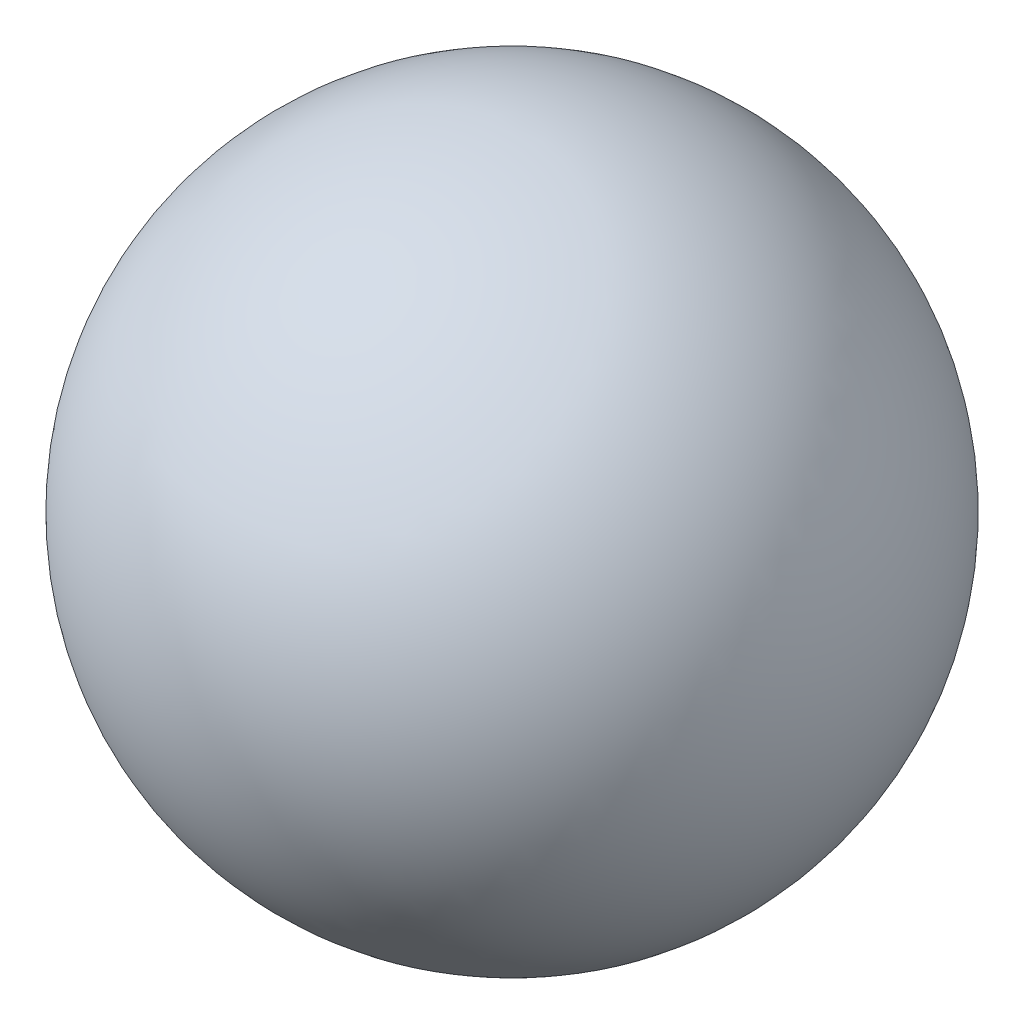
from build123d import *


with BuildPart() as part:
    # Sketch1 → Revolve1 (revolve)
    with BuildSketch(Plane.XY):
        with BuildLine():
            Line((-690.550000025, 937.399999974), (-690.550000025, 637.400000026))
            ThreePointArc((-690.550000025, 637.400000026), (-840.549999999, 787.4), (-690.550000025, 937.399999974))
        make_face()
    revolve(axis=Axis((-690.550000025, 937.399999974, 0), (0, -1, 0)))


solid = part.part
